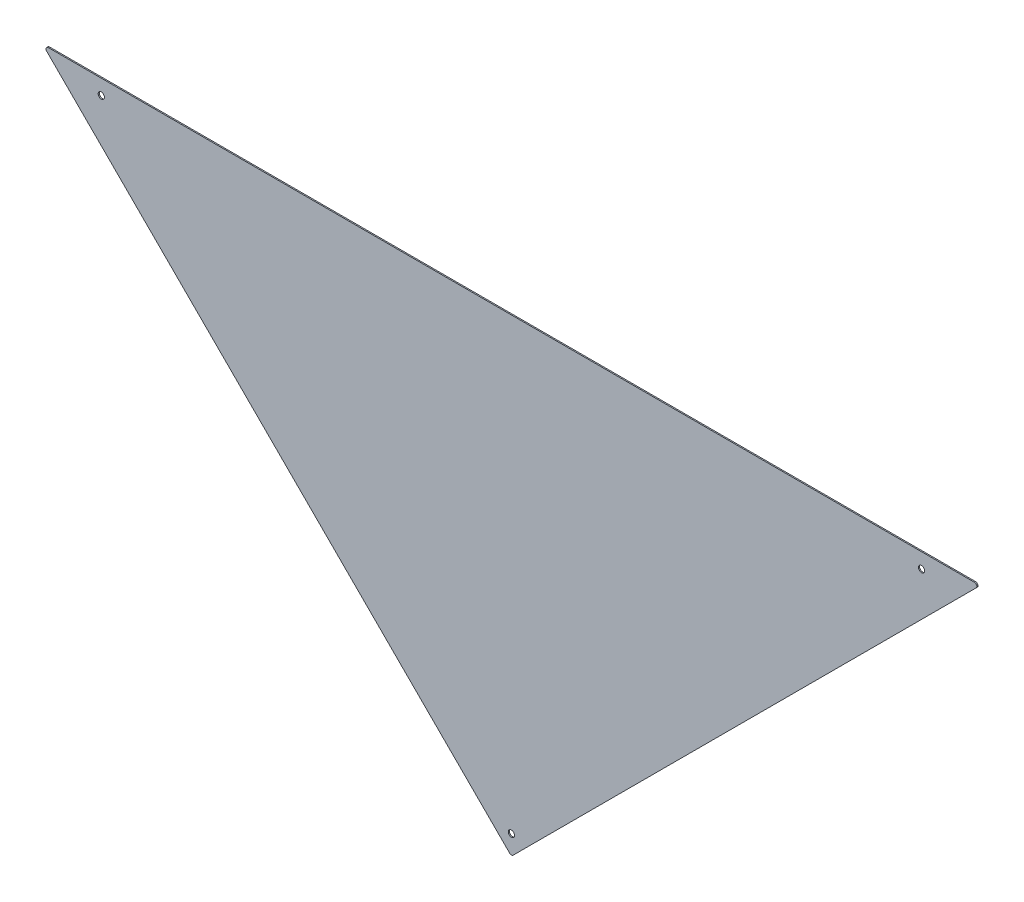
from build123d import *

# Parameters (mm, degrees)
SKETCH1_R           = 4
BOSS_EXTRUDE1_DEPTH = 1.5


with BuildPart() as part:
    # Sketch1 → Boss-Extrude1 (new body)
    with BuildSketch(Plane.XY):
        with BuildLine():
            ThreePointArc((-2.121320344, 6.363961031), (0, 5.485281374), (2.121320344, 6.363961031))
            Line((2.121320344, 6.363961031), (594.878679656, 599.121320344))
            ThreePointArc((594.878679656, 599.121320344), (595.52899791, 602.390690984), (592.757359313, 604.242640687))
            Line((592.757359313, 604.242640687), (-592.757359313, 604.242640687))
            ThreePointArc((-592.757359313, 604.242640687), (-595.52899791, 602.390690984), (-594.878679656, 599.121320344))
            Line((-594.878679656, 599.121320344), (-2.121320344, 6.363961031))
        make_face()
        with Locations((0, 29.242640687)):
            Circle(SKETCH1_R, mode=Mode.SUBTRACT)
        with Locations((-525, 585)):
            Circle(SKETCH1_R, mode=Mode.SUBTRACT)
        with Locations((525, 585)):
            Circle(SKETCH1_R, mode=Mode.SUBTRACT)
    extrude(amount=BOSS_EXTRUDE1_DEPTH)


solid = part.part
